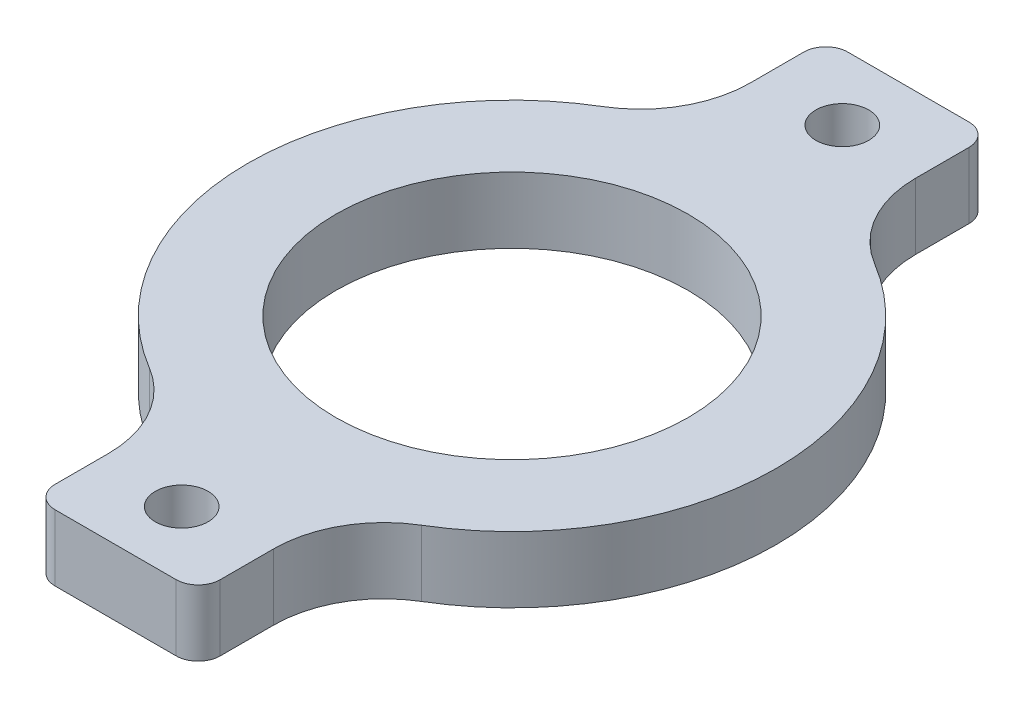
from build123d import *

# Parameters (mm, degrees)
SKETCH1_R            = 8
BOSS_EXTRUDE1_DEPTH  = 3
M2_CLEARANCE_HOLE1_D = 2.4
FILLET1_R            = 5
FILLET2_R            = 1


with BuildPart() as part:
    # Sketch1 → Boss-Extrude1 (new body)
    with BuildSketch(Plane(origin=(0, 0, 0), x_dir=(1, 0, 0), z_dir=(0, 1, 0))):
        with BuildLine():
            Line((-3.75, 18), (3.75, 18))
            Line((3.75, 18), (3.75, 11.399013115))
            ThreePointArc((3.75, 11.399013115), (12, 0), (3.75, -11.399013115))
            Line((3.75, -11.399013115), (3.75, -18))
            Line((3.75, -18), (-3.75, -18))
            Line((-3.75, -18), (-3.75, -11.399013115))
            ThreePointArc((-3.75, -11.399013115), (-12, 0), (-3.75, 11.399013115))
            Line((-3.75, 11.399013115), (-3.75, 18))
        make_face()
        Circle(SKETCH1_R, mode=Mode.SUBTRACT)
    extrude(amount=BOSS_EXTRUDE1_DEPTH)

    # M2 Clearance Hole1 (through all)
    with Locations(Plane(origin=(0, 3, 0), x_dir=(1, 0, 0), z_dir=(0, 1, 0))):
        with Locations((0, -15), (0, 15)):
            Hole(M2_CLEARANCE_HOLE1_D / 2)

    # Fillet1
    fillet1_edges = [part.edges().sort_by_distance(p)[0] for p in [
        (3.75, 1.5, -11.399013115),
        (3.75, 1.5, 11.399013115),
        (-3.75, 1.5, 11.399013115),
        (-3.75, 1.5, -11.399013115),
    ]]
    fillet(fillet1_edges, radius=FILLET1_R)

    # Fillet2
    fillet2_edges = [part.edges().sort_by_distance(p)[0] for p in [
        (3.75, 1.5, 18),
        (-3.75, 1.5, 18),
        (-3.75, 1.5, -18),
        (3.75, 1.5, -18),
    ]]
    fillet(fillet2_edges, radius=FILLET2_R)


solid = part.part
